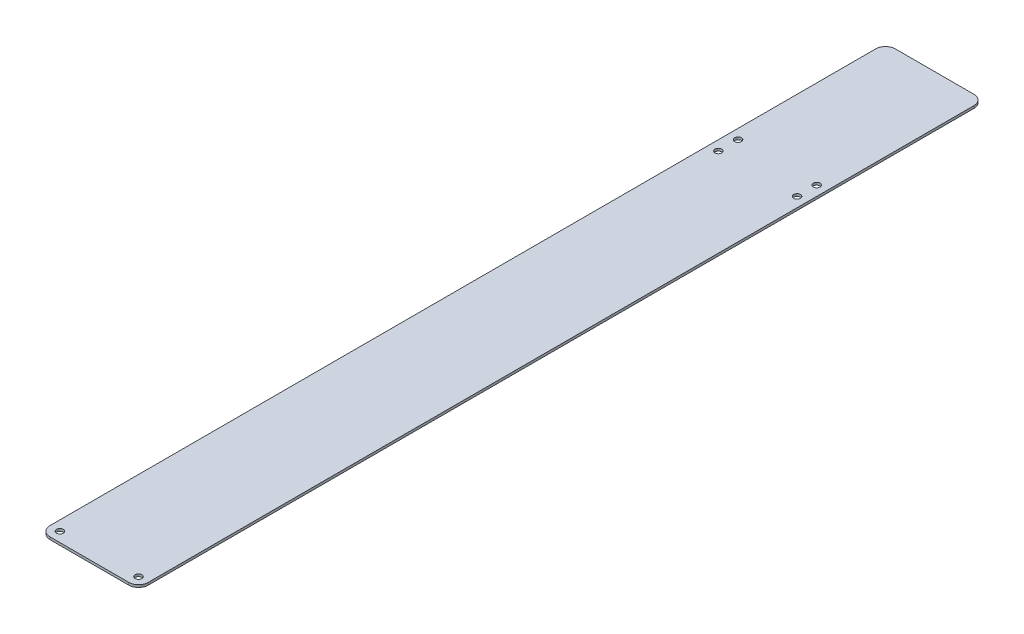
from build123d import *

# Parameters (mm, degrees)
SKETCH1_R           = 2.1828125
BOSS_EXTRUDE1_DEPTH = 0.79375


with BuildPart() as part:
    # Sketch1 → Boss-Extrude1 (new body, symmetric)
    with BuildSketch(Plane(origin=(0, 0, 0), x_dir=(1, 0, 0), z_dir=(0, 1, 0))):
        with BuildLine():
            Line((6.35, 0), (57.15, 0))
            ThreePointArc((57.15, 0), (61.640128061, 1.859871939), (63.5, 6.35))
            Line((63.5, 6.35), (63.5, 539.75))
            ThreePointArc((63.5, 539.75), (61.640128061, 544.240128061), (57.15, 546.1))
            Line((57.15, 546.1), (6.35, 546.1))
            ThreePointArc((6.35, 546.1), (1.859871939, 544.240128061), (0, 539.75))
            Line((0, 539.75), (0, 6.35))
            ThreePointArc((0, 6.35), (1.859871939, 1.859871939), (6.35, 0))
        make_face()
        with Locations((6.35, 6.35)):
            Circle(SKETCH1_R, mode=Mode.SUBTRACT)
        with Locations((57.15, 6.35)):
            Circle(SKETCH1_R, mode=Mode.SUBTRACT)
        with Locations((6.35, 431.8)):
            Circle(SKETCH1_R, mode=Mode.SUBTRACT)
        with Locations((6.35, 444.5)):
            Circle(SKETCH1_R, mode=Mode.SUBTRACT)
        with Locations((57.15, 431.8)):
            Circle(SKETCH1_R, mode=Mode.SUBTRACT)
        with Locations((57.15, 444.5)):
            Circle(SKETCH1_R, mode=Mode.SUBTRACT)
    extrude(amount=BOSS_EXTRUDE1_DEPTH, both=True)


solid = part.part
